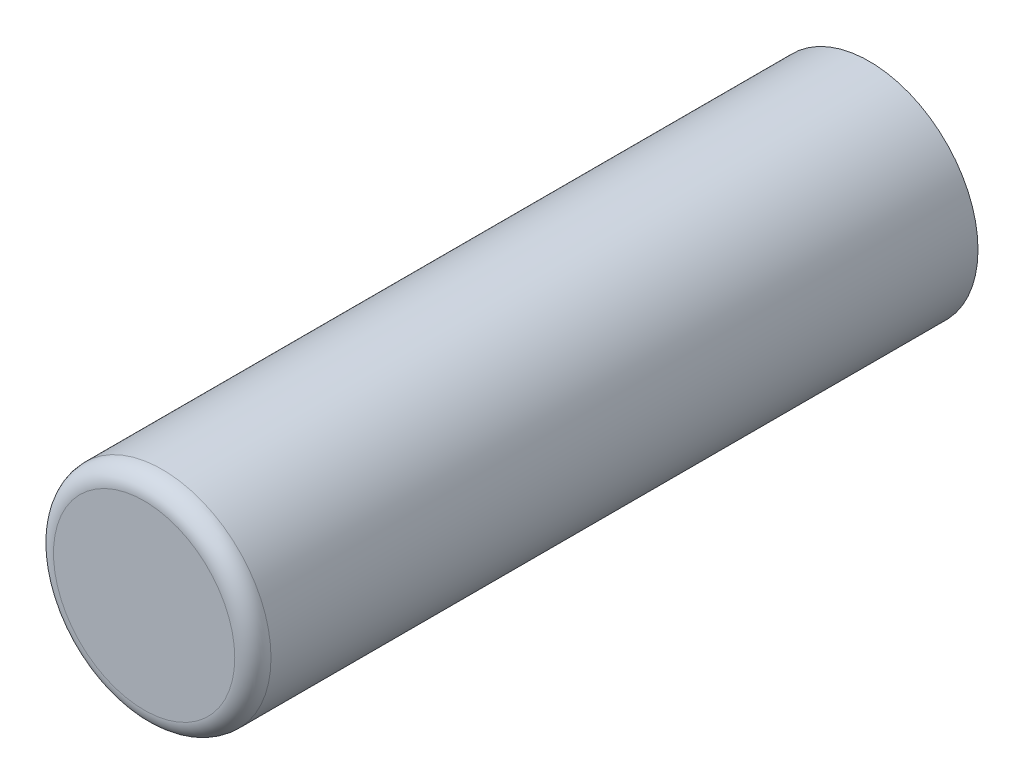
from build123d import *

# Parameters (mm, degrees)
SKETCH1_R           = 4.8
BOSS_EXTRUDE1_DEPTH = 16
FILLET1_R           = 0.8


with BuildPart() as part:
    # Sketch1 → Boss-Extrude1 (new body, symmetric)
    with BuildSketch(Plane.XY):
        Circle(SKETCH1_R)
    extrude(amount=BOSS_EXTRUDE1_DEPTH, both=True)

    # Fillet1
    fillet1_edges = [part.edges().sort_by_distance(p)[0] for p in [
        (-4.8, 0, 16),
    ]]
    fillet(fillet1_edges, radius=FILLET1_R)


solid = part.part
